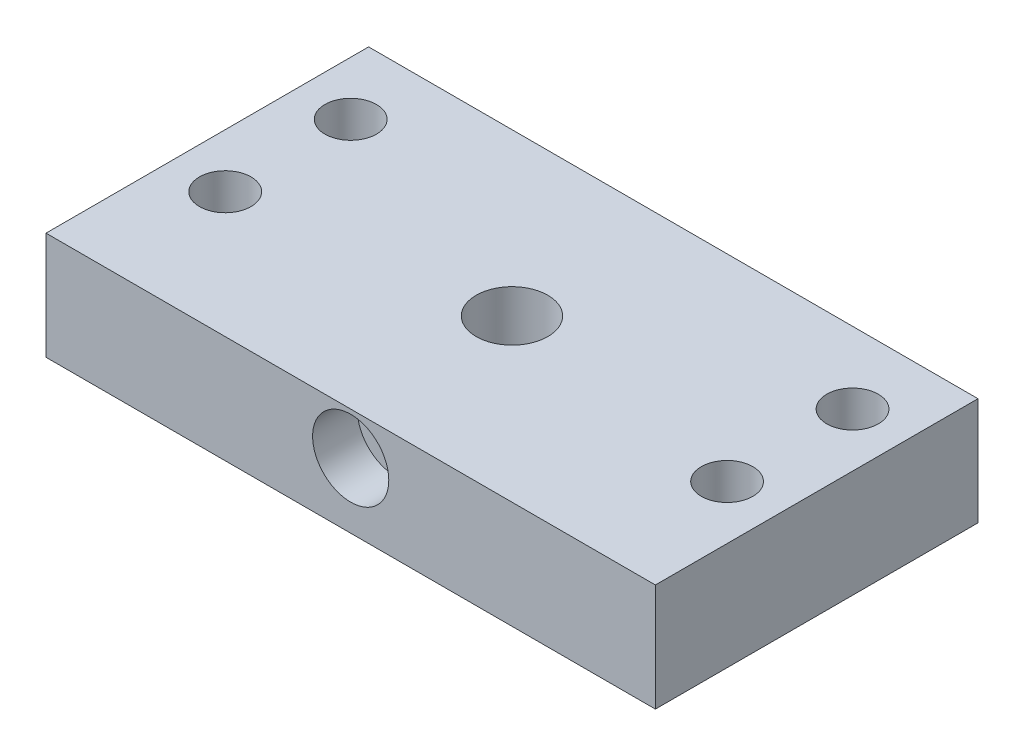
from build123d import *

# Parameters (mm, degrees)
SKETCH1_W           = 68
SKETCH1_H           = 36
BOSS_EXTRUDE1_DEPTH = 12
SKETCH2_R           = 11
CUT_EXTRUDE1_DEPTH  = 4
SKETCH3_R           = 4
CUT_EXTRUDE2_DEPTH  = 9
CUT_EXTRUDE3_REACH  = 38
SKETCH4_R           = 2.375
CUT_EXTRUDE4_REACH  = 14
SKETCH5_R           = 2.875
SKETCH6_R           = 5
CUT_EXTRUDE5_DEPTH  = 6
SKETCH7_R           = 4.25
CUT_EXTRUDE6_DEPTH  = 5


with BuildPart() as part:
    # Sketch1 → Boss-Extrude1 (new body)
    with BuildSketch(Plane(origin=(0, 0, 0), x_dir=(1, 0, 0), z_dir=(0, 1, 0))):
        Rectangle(SKETCH1_W, SKETCH1_H)
    extrude(amount=BOSS_EXTRUDE1_DEPTH)

    # Sketch2 → Cut-Extrude1 (cut)
    with BuildSketch(Plane.XZ):
        Circle(SKETCH2_R)
    extrude(amount=-CUT_EXTRUDE1_DEPTH, mode=Mode.SUBTRACT)

    # Sketch3 → Cut-Extrude2 (cut, through all)
    with BuildSketch(Plane.XZ.offset(-4)):
        Circle(SKETCH3_R)
    extrude(amount=-CUT_EXTRUDE2_DEPTH, mode=Mode.SUBTRACT)

    # Sketch4 → Cut-Extrude3 (cut, up to next)
    with BuildSketch(Plane.XY.offset(18), mode=Mode.PRIVATE) as cut_extrude3_sk1:
        with Locations((0, 7.25)):
            Circle(SKETCH4_R)
    cut_extrude3_tool1 = extrude(cut_extrude3_sk1.sketch, amount=-CUT_EXTRUDE3_REACH, mode=Mode.PRIVATE) & part.part
    add(cut_extrude3_tool1.solids().sort_by_distance((0, 7.25, 18))[0], mode=Mode.SUBTRACT)

    # Sketch5 → Cut-Extrude4 (cut, up to next)
    with BuildSketch(Plane.XZ, mode=Mode.PRIVATE) as cut_extrude4_sk1:
        with Locations((28, 4)):
            Circle(SKETCH5_R)
    cut_extrude4_tool1 = extrude(cut_extrude4_sk1.sketch, amount=-CUT_EXTRUDE4_REACH, mode=Mode.PRIVATE) & part.part
    add(cut_extrude4_tool1.solids().sort_by_distance((28, 0, 4))[0], mode=Mode.SUBTRACT)
    # Sketch5 → Cut-Extrude4 (cut, up to next)
    with BuildSketch(Plane.XZ, mode=Mode.PRIVATE) as cut_extrude4_sk2:
        with Locations((28, -10)):
            Circle(SKETCH5_R)
    cut_extrude4_tool2 = extrude(cut_extrude4_sk2.sketch, amount=-CUT_EXTRUDE4_REACH, mode=Mode.PRIVATE) & part.part
    add(cut_extrude4_tool2.solids().sort_by_distance((28, 0, -10))[0], mode=Mode.SUBTRACT)
    # Sketch5 → Cut-Extrude4 (cut, up to next)
    with BuildSketch(Plane.XZ, mode=Mode.PRIVATE) as cut_extrude4_sk3:
        with Locations((-28, 4)):
            Circle(SKETCH5_R)
    cut_extrude4_tool3 = extrude(cut_extrude4_sk3.sketch, amount=-CUT_EXTRUDE4_REACH, mode=Mode.PRIVATE) & part.part
    add(cut_extrude4_tool3.solids().sort_by_distance((-28, 0, 4))[0], mode=Mode.SUBTRACT)
    # Sketch5 → Cut-Extrude4 (cut, up to next)
    with BuildSketch(Plane.XZ, mode=Mode.PRIVATE) as cut_extrude4_sk4:
        with Locations((-28, -10)):
            Circle(SKETCH5_R)
    cut_extrude4_tool4 = extrude(cut_extrude4_sk4.sketch, amount=-CUT_EXTRUDE4_REACH, mode=Mode.PRIVATE) & part.part
    add(cut_extrude4_tool4.solids().sort_by_distance((-28, 0, -10))[0], mode=Mode.SUBTRACT)

    # Sketch6 → Cut-Extrude5 (cut)
    with BuildSketch(Plane.XZ):
        with Locations((-28, 4)):
            Circle(SKETCH6_R)
        with Locations((28, 4)):
            Circle(SKETCH6_R)
        with Locations((28, -10)):
            Circle(SKETCH6_R)
        with Locations((-28, -10)):
            Circle(SKETCH6_R)
    extrude(amount=-CUT_EXTRUDE5_DEPTH, mode=Mode.SUBTRACT)

    # Sketch7 → Cut-Extrude6 (cut)
    with BuildSketch(Plane.XY.offset(18)):
        with Locations((0, 7.25)):
            Circle(SKETCH7_R)
    extrude(amount=-CUT_EXTRUDE6_DEPTH, mode=Mode.SUBTRACT)


solid = part.part
